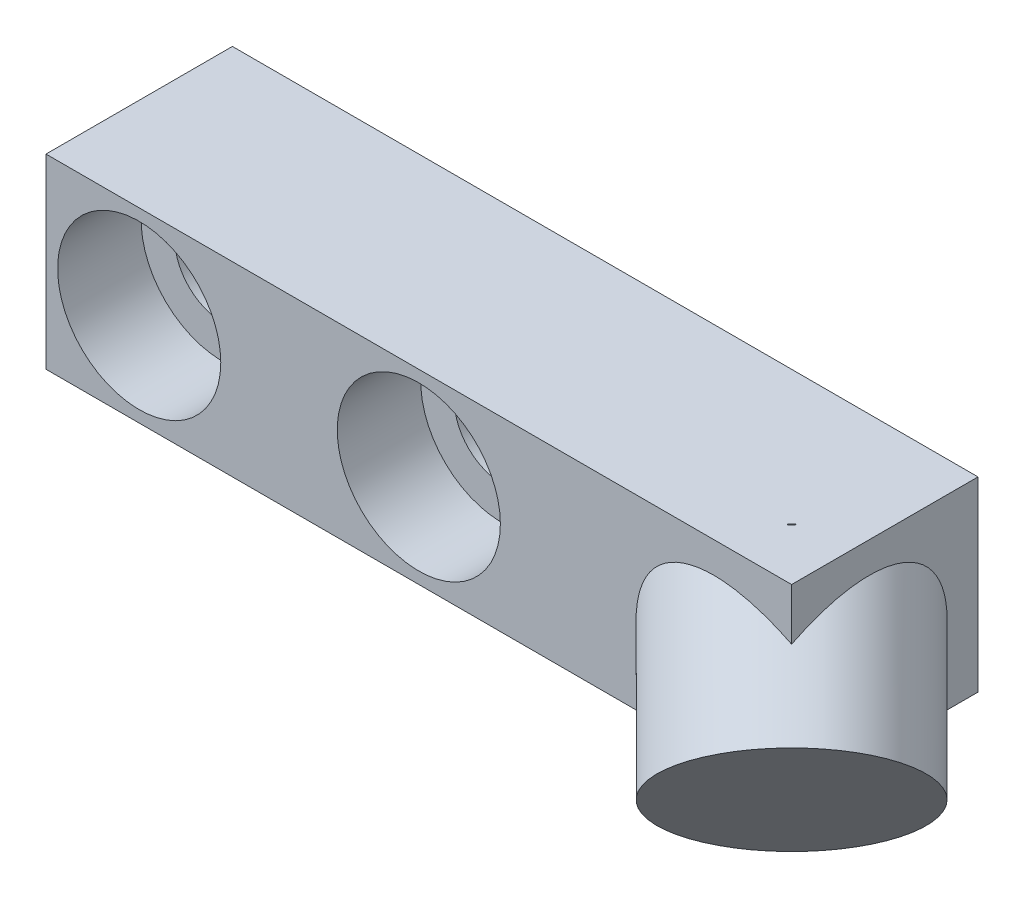
from build123d import *

# Parameters (mm, degrees)
SKETCH1_W                                      = 25.4
SKETCH1_H                                      = 6.35
BOSS_EXTRUDE1_DEPTH                            = 6.35
CBORE_FOR_4_SOCKET_HEAD_CAP_SCREW1_D           = 3.2639
CBORE_FOR_4_SOCKET_HEAD_CAP_SCREW1_DEPTH       = 7.5946
CBORE_FOR_4_SOCKET_HEAD_CAP_SCREW1_CBORE_D     = 5.55752
CBORE_FOR_4_SOCKET_HEAD_CAP_SCREW1_CBORE_DEPTH = 2.8448
CBORE_FOR_4_SOCKET_HEAD_CAP_SCREW1_TIP         = 0.980574487
SKETCH4_R                                      = 3.7465
BOSS_EXTRUDE2_DEPTH                            = 5.715


with BuildPart() as part:
    # Sketch1 → Boss-Extrude1 (new body)
    with BuildSketch(Plane.XY):
        Rectangle(SKETCH1_W, SKETCH1_H)
    extrude(amount=BOSS_EXTRUDE1_DEPTH)

    # CBORE for _4 Socket Head Cap Screw1
    with Locations(Plane.XY.offset(6.35)):
        with Locations((-9.525, 0), (0, 0)):
            CounterBoreHole(CBORE_FOR_4_SOCKET_HEAD_CAP_SCREW1_D / 2, CBORE_FOR_4_SOCKET_HEAD_CAP_SCREW1_CBORE_D / 2, CBORE_FOR_4_SOCKET_HEAD_CAP_SCREW1_CBORE_DEPTH, depth=CBORE_FOR_4_SOCKET_HEAD_CAP_SCREW1_DEPTH)
            with Locations((0, 0, -(CBORE_FOR_4_SOCKET_HEAD_CAP_SCREW1_DEPTH + CBORE_FOR_4_SOCKET_HEAD_CAP_SCREW1_TIP / 2))):  # 118° drill point
                Cone(0, CBORE_FOR_4_SOCKET_HEAD_CAP_SCREW1_D / 2, CBORE_FOR_4_SOCKET_HEAD_CAP_SCREW1_TIP, mode=Mode.SUBTRACT)

    # Sketch4 → Boss-Extrude2 (add)
    with BuildSketch(Plane(origin=(12.7, -3.175, 6.35), x_dir=(0.40824829, -0.40824829, -0.816496581), z_dir=(0.577350269, -0.577350269, 0.577350269))):
        Circle(SKETCH4_R)
    extrude(amount=-BOSS_EXTRUDE2_DEPTH)


solid = part.part
